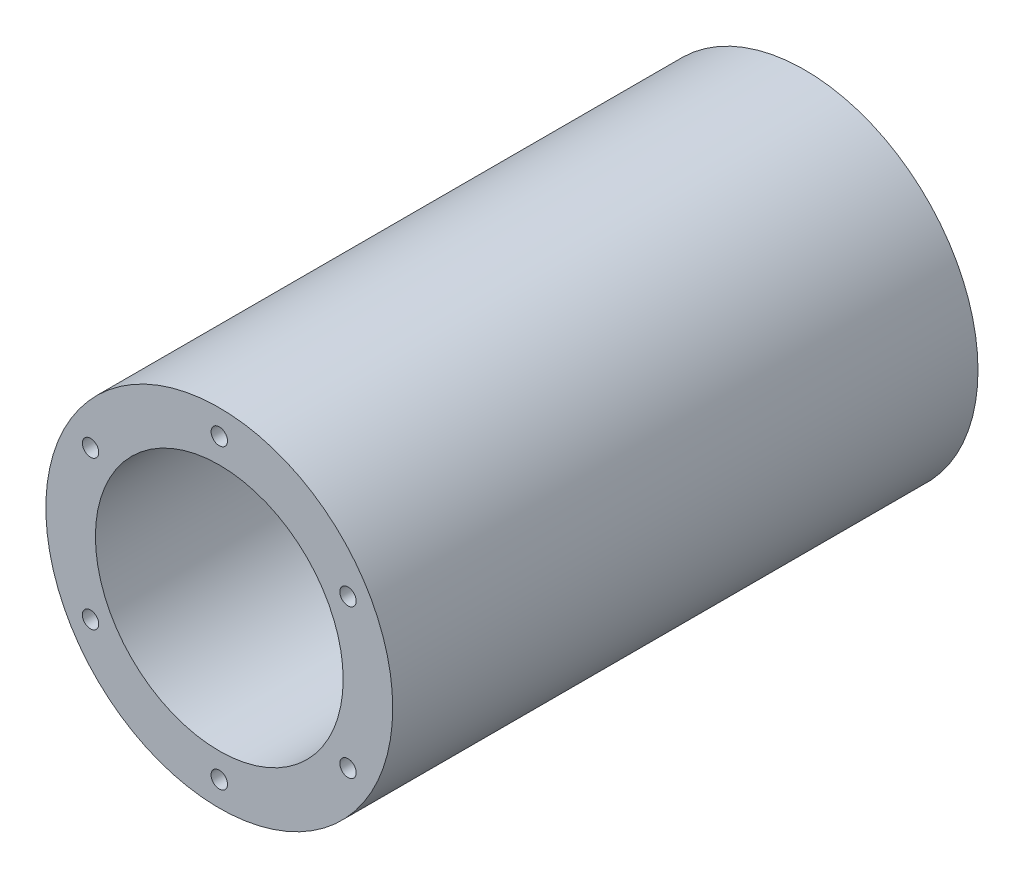
from build123d import *

# Parameters (mm, degrees)
SKETCH1_R           = 44.45
SKETCH1_R_2         = 31.75
BOSS_EXTRUDE1_DEPTH = 75
CIRPATTERN1_COUNT   = 6


with BuildPart() as part:
    # Sketch1 → Boss-Extrude1 (new body, symmetric)
    with BuildSketch(Plane.XY):
        Circle(SKETCH1_R)
        Circle(SKETCH1_R_2, mode=Mode.SUBTRACT)
    extrude(amount=BOSS_EXTRUDE1_DEPTH, both=True)

    # Sketch3 → M5x0.8 Tapped Hole1 (revolve, cut)
    with BuildSketch(Plane(origin=(0, 38.1, 75), x_dir=(0, -1, 0), z_dir=(1, 0, 0))):
        Polygon((0, 0), (0, 13.6618073), (2.1, 12.4), (2.1, 0), align=None)
    m5x0_8_tapped_hole1 = revolve(axis=Axis((0, 38.1, 81.35), (0, 0, -1)), mode=Mode.SUBTRACT)

    # CirPattern1: M5x0.8 Tapped Hole1 ×6 about axis
    cirpattern1_axis = Axis((0, 0, 0), (0, 0, 1))
    for i in range(1, CIRPATTERN1_COUNT):
        add(m5x0_8_tapped_hole1.rotate(cirpattern1_axis, i * 360 / CIRPATTERN1_COUNT), mode=Mode.SUBTRACT)

    # Mirror1: M5x0.8 Tapped Hole1 across plane
    add(m5x0_8_tapped_hole1.mirror(Plane.XY), mode=Mode.SUBTRACT)

    # Mirror1 copy 1 sketch → Mirror1 copy 1 (revolve, cut)
    with BuildSketch(Plane(origin=(-32.995567884, 19.05, -75), x_dir=(0.866025404, -0.5, 0), z_dir=(0.5, 0.866025404, 0))):
        Polygon((0, 0), (0, -13.6618073), (2.1, -12.4), (2.1, 0), align=None)
    revolve(axis=Axis((-32.995567884, 19.05, -81.35), (0, 0, -1)), mode=Mode.SUBTRACT)

    # Mirror1 copy 2 sketch → Mirror1 copy 2 (revolve, cut)
    with BuildSketch(Plane(origin=(-32.995567884, -19.05, -75), x_dir=(0.866025404, 0.5, 0), z_dir=(-0.5, 0.866025404, 0))):
        Polygon((0, 0), (0, -13.6618073), (2.1, -12.4), (2.1, 0), align=None)
    revolve(axis=Axis((-32.995567884, -19.05, -81.35), (0, 0, -1)), mode=Mode.SUBTRACT)

    # Mirror1 copy 3 sketch → Mirror1 copy 3 (revolve, cut)
    with BuildSketch(Plane(origin=(0, -38.1, -75), x_dir=(0, 1, 0), z_dir=(-1, 0, 0))):
        Polygon((0, 0), (0, -13.6618073), (2.1, -12.4), (2.1, 0), align=None)
    revolve(axis=Axis((0, -38.1, -81.35), (0, 0, -1)), mode=Mode.SUBTRACT)

    # Mirror1 copy 4 sketch → Mirror1 copy 4 (revolve, cut)
    with BuildSketch(Plane(origin=(32.995567884, -19.05, -75), x_dir=(-0.866025404, 0.5, 0), z_dir=(-0.5, -0.866025404, 0))):
        Polygon((0, 0), (0, -13.6618073), (2.1, -12.4), (2.1, 0), align=None)
    revolve(axis=Axis((32.995567884, -19.05, -81.35), (0, 0, -1)), mode=Mode.SUBTRACT)

    # Mirror1 copy 5 sketch → Mirror1 copy 5 (revolve, cut)
    with BuildSketch(Plane(origin=(32.995567884, 19.05, -75), x_dir=(-0.866025404, -0.5, 0), z_dir=(0.5, -0.866025404, 0))):
        Polygon((0, 0), (0, -13.6618073), (2.1, -12.4), (2.1, 0), align=None)
    revolve(axis=Axis((32.995567884, 19.05, -81.35), (0, 0, -1)), mode=Mode.SUBTRACT)


solid = part.part
